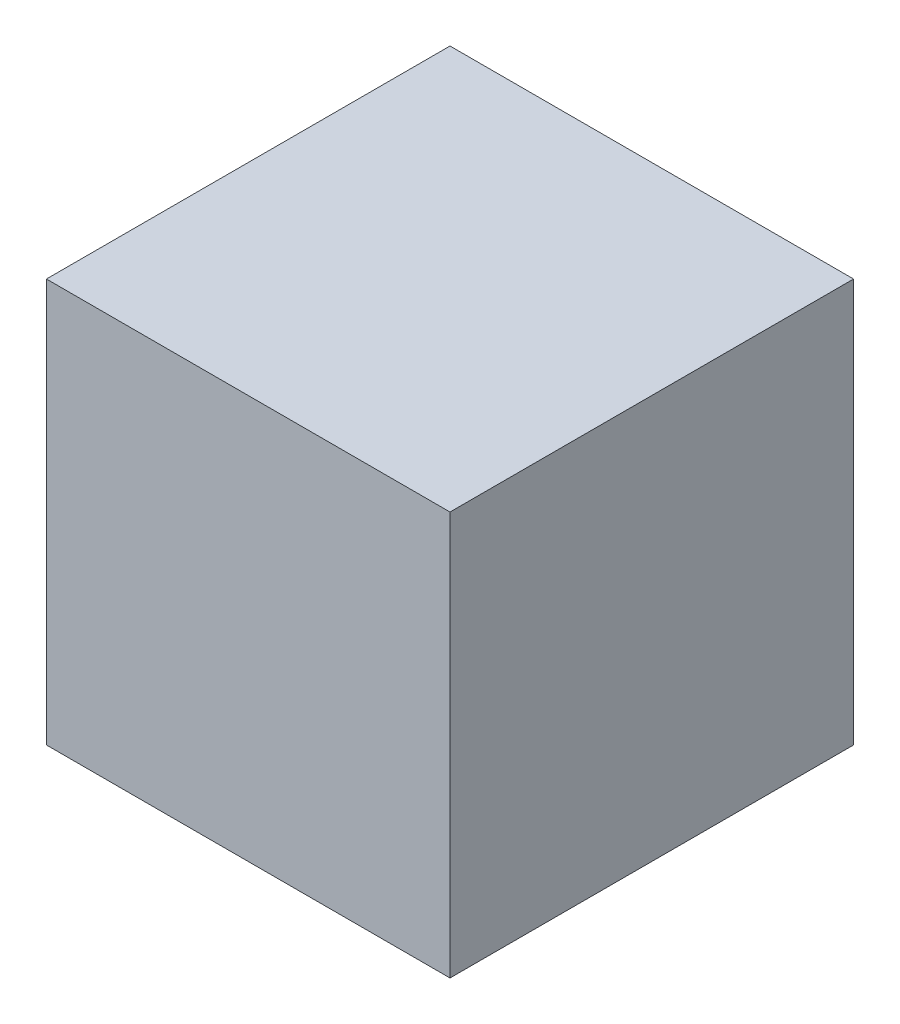
from build123d import *

# Parameters (mm, degrees)
SKETCH_1_W      = 70
SKETCH_1_H      = 70
EXTRUDE_1_DEPTH = 70


with BuildPart() as part:
    # 草图1 → 凸台-拉伸1 (new body)
    with BuildSketch(Plane(origin=(0, 0, 0), x_dir=(1, 0, 0), z_dir=(0, 1, 0))):
        with Locations((35, 35)):
            Rectangle(SKETCH_1_W, SKETCH_1_H)
    extrude(amount=EXTRUDE_1_DEPTH)


solid = part.part
